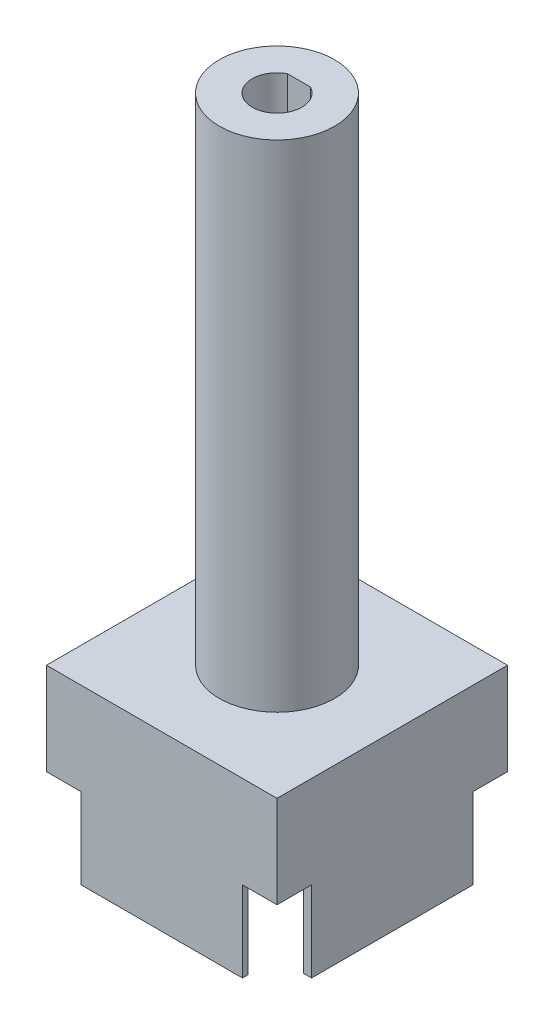
from build123d import *

# Parameters (mm, degrees)
SKETCH_1_W          = 20
SKETCH_1_H          = 20
SKETCH_1_W_2        = 18.8
SKETCH_1_H_2        = 19
EXTRUDE_1_DEPTH     = 7
SKETCH_3_W          = 20
SKETCH_3_H          = 20
EXTRUDE_2_DEPTH     = 8
SKETCH_4_R          = 5
EXTRUDE_3_DEPTH     = 43
CUT_EXTRUDE_1_DEPTH = 18
SKETCH_6_W          = 3
SKETCH_6_H          = 3
CUT_EXTRUDE_2_DEPTH = 10


with BuildPart() as part:
    # 草圖1 → 填料-伸長1 (new body)
    with BuildSketch(Plane(origin=(0, 0, 0), x_dir=(1, 0, 0), z_dir=(0, 1, 0))):
        with Locations((10, 10)):
            Rectangle(SKETCH_1_W, SKETCH_1_H)
        with Locations((9.9, 10)):
            Rectangle(SKETCH_1_W_2, SKETCH_1_H_2, mode=Mode.SUBTRACT)
    extrude(amount=EXTRUDE_1_DEPTH)

    # 草圖3 → 填料-伸長2 (add)
    with BuildSketch(Plane(origin=(0, 7, 0), x_dir=(1, 0, 0), z_dir=(0, 1, 0))):
        with Locations((10, 10)):
            Rectangle(SKETCH_3_W, SKETCH_3_H)
    extrude(amount=EXTRUDE_2_DEPTH)

    # 草圖4 → 填料-伸長3 (add)
    with BuildSketch(Plane(origin=(0, 15, 0), x_dir=(1, 0, 0), z_dir=(0, 1, 0))):
        with Locations((10, 10)):
            Circle(SKETCH_4_R)
    extrude(amount=EXTRUDE_3_DEPTH)

    # 草圖5 → 除料-伸長1 (cut)
    with BuildSketch(Plane(origin=(0, 58, 0), x_dir=(1, 0, 0), z_dir=(0, 1, 0))):
        with BuildLine():
            Line((10, 11.9), (8.99376941, 11.9))
            ThreePointArc((8.99376941, 11.9), (8.891148289, 8.158004375), (12.15, 10))
            ThreePointArc((12.15, 10), (11.841995625, 11.108851711), (11.00623059, 11.9))
            Line((11.00623059, 11.9), (10, 11.9))
        make_face()
    extrude(amount=-CUT_EXTRUDE_1_DEPTH, mode=Mode.SUBTRACT)

    # 草圖6 → 除料-伸長2 (cut)
    with BuildSketch(Plane(origin=(0, 7, 0), x_dir=(1, 0, 0), z_dir=(0, 1, 0))):
        with Locations((1.5, 18.5)):
            Rectangle(SKETCH_6_W, SKETCH_6_H)
        with Locations((18.5, 18.5)):
            Rectangle(SKETCH_6_W, SKETCH_6_H)
        with Locations((18.5, 1.5)):
            Rectangle(SKETCH_6_W, SKETCH_6_H)
        with Locations((1.5, 1.5)):
            Rectangle(SKETCH_6_W, SKETCH_6_H)
    extrude(amount=-CUT_EXTRUDE_2_DEPTH, mode=Mode.SUBTRACT)


solid = part.part
